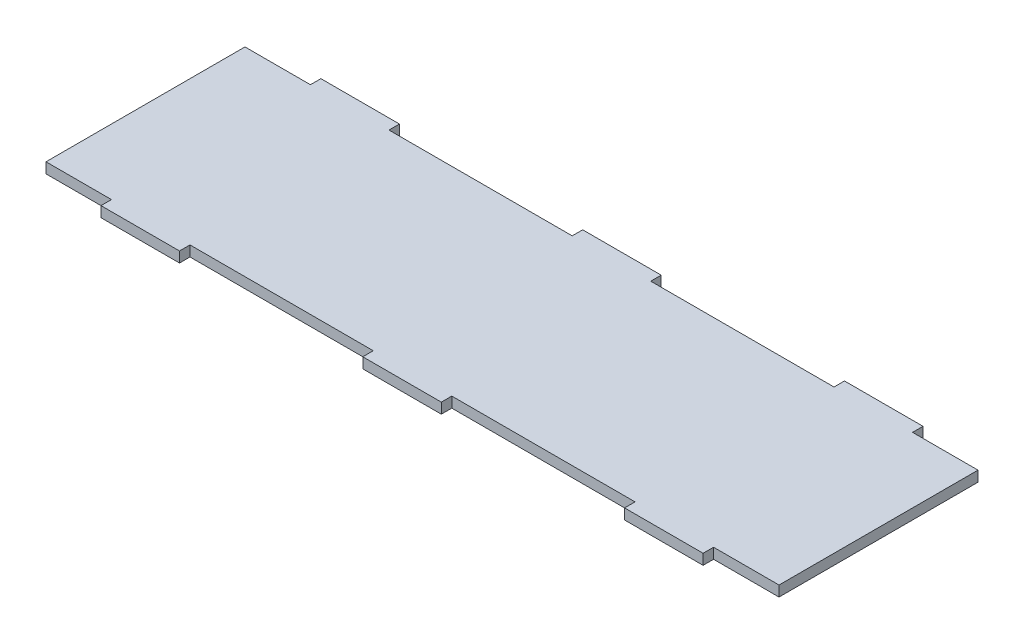
from build123d import *

# Parameters (mm, degrees)
RESSALTO_EXTRUS_O1_DEPTH = 4


with BuildPart() as part:
    # Esboço1 → Ressalto-extrusão1 (new body)
    with BuildSketch(Plane(origin=(0, 0, 0), x_dir=(1, 0, 0), z_dir=(0, 1, 0))):
        Polygon((15, 0), (-15, 0), (-15, 4), (-85, 4), (-85, 0), (-115, 0), (-115, 4), (-140, 4), (-140, 80), (-115, 80), (-115, 84), (-85, 84), (-85, 80), (-15, 80), (-15, 84), (15, 84), (15, 80), (85, 80), (85, 84), (115, 84), (115, 80), (140, 80), (140, 4), (115, 4), (115, 0), (85, 0), (85, 4), (15, 4), align=None)
    extrude(amount=RESSALTO_EXTRUS_O1_DEPTH)


solid = part.part
